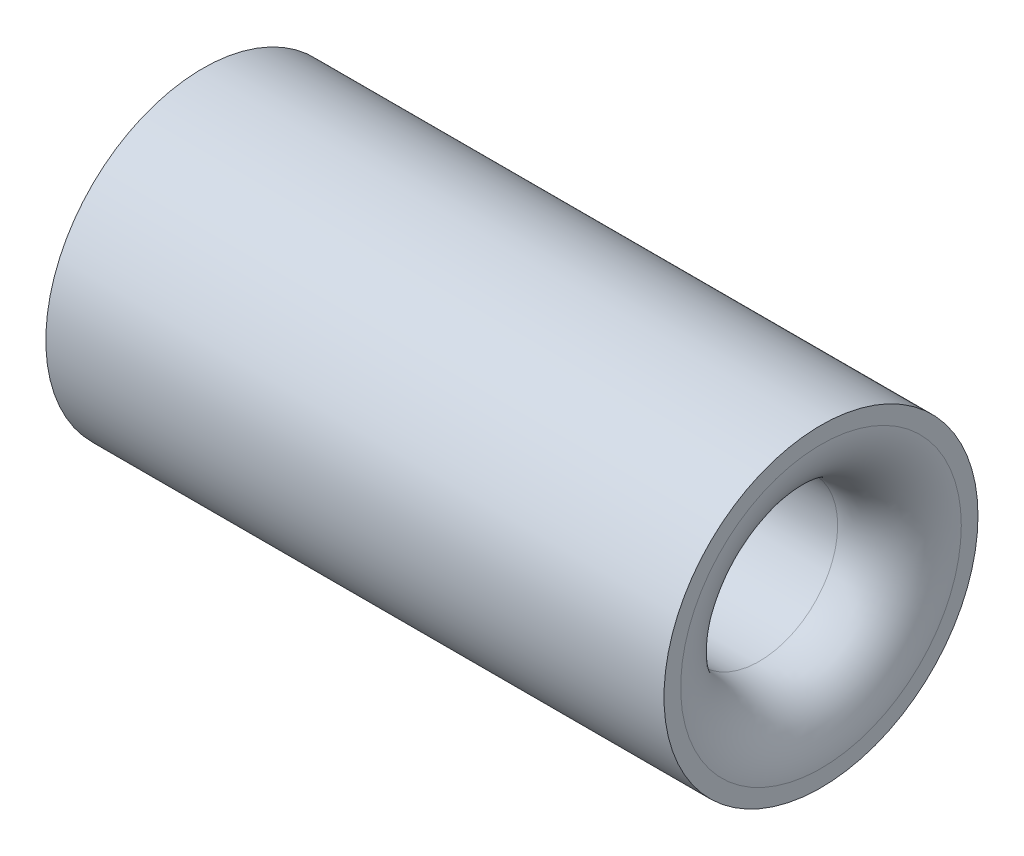
from build123d import *

# Parameters (mm, degrees)
SKETCH1_R           = 12.7
BOSS_EXTRUDE1_DEPTH = 50
SKETCH2_R           = 6.35
CUT_EXTRUDE1_DEPTH  = 51
FILLET1_R           = 5


with BuildPart() as part:
    # Sketch1 → Boss-Extrude1 (new body)
    with BuildSketch(Plane(origin=(0, 0, 0), x_dir=(0, 0, -1), z_dir=(1, 0, 0))):
        Circle(SKETCH1_R)
    extrude(amount=BOSS_EXTRUDE1_DEPTH)

    # Sketch2 → Cut-Extrude1 (cut, through all)
    with BuildSketch(Plane(origin=(50, 0, 0), x_dir=(0, 0, -1), z_dir=(1, 0, 0))):
        Circle(SKETCH2_R)
    extrude(amount=-CUT_EXTRUDE1_DEPTH, mode=Mode.SUBTRACT)

    # Fillet1
    fillet1_edges = [part.edges().sort_by_distance(p)[0] for p in [
        (50, 0, 6.35),
    ]]
    fillet(fillet1_edges, radius=FILLET1_R)


solid = part.part
